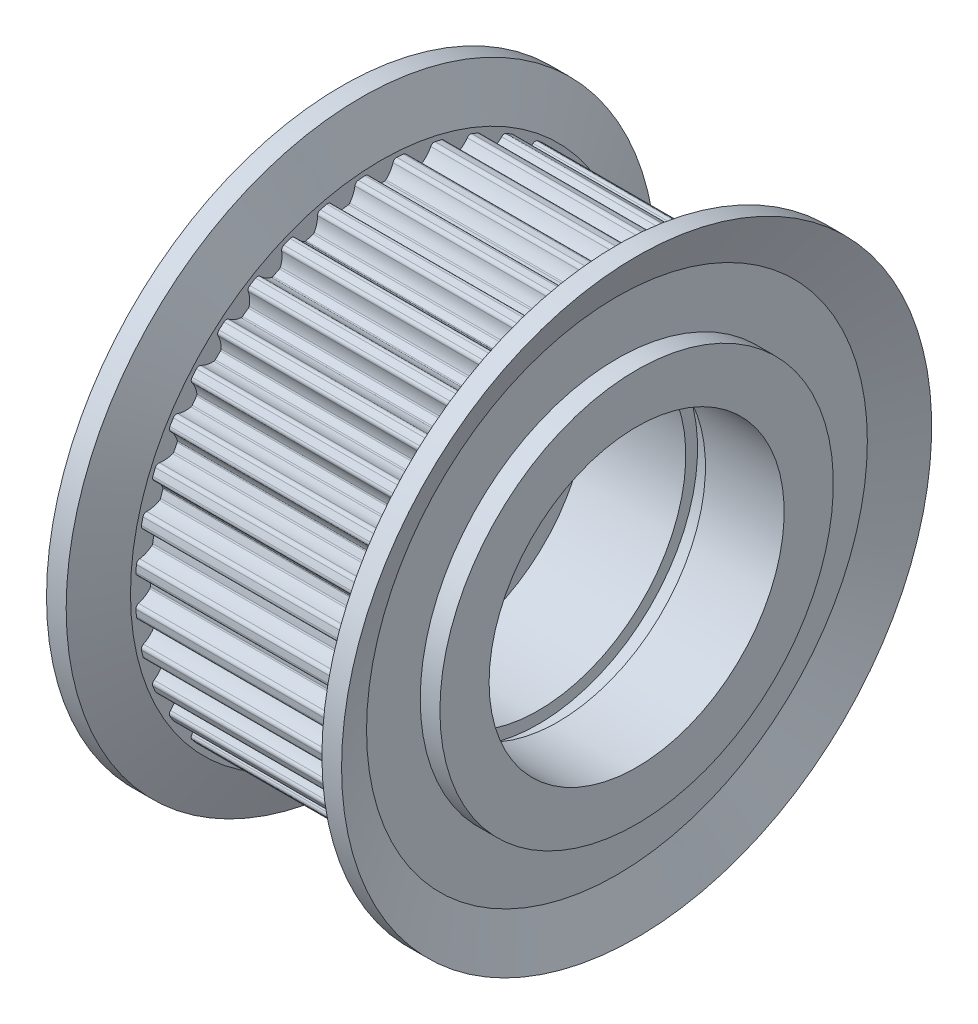
from build123d import *

# Parameters (mm, degrees)
CUT_EXTRUDE1_DEPTH  = 11
CUT_EXTRUDE2_DEPTH  = 11
CUT_EXTRUDE3_DEPTH  = 11
CUT_EXTRUDE4_DEPTH  = 11
CUT_EXTRUDE5_DEPTH  = 11
CUT_EXTRUDE6_DEPTH  = 11
CUT_EXTRUDE7_DEPTH  = 11
CUT_EXTRUDE8_DEPTH  = 11
CUT_EXTRUDE9_DEPTH  = 11
CUT_EXTRUDE10_DEPTH = 11
CUT_EXTRUDE11_DEPTH = 11
CUT_EXTRUDE12_DEPTH = 11
CUT_EXTRUDE13_DEPTH = 11
CUT_EXTRUDE14_DEPTH = 11
CUT_EXTRUDE15_DEPTH = 11
CUT_EXTRUDE16_DEPTH = 11
CUT_EXTRUDE17_DEPTH = 11
CUT_EXTRUDE18_DEPTH = 11
CUT_EXTRUDE19_DEPTH = 11
CUT_EXTRUDE20_DEPTH = 11
CUT_EXTRUDE21_DEPTH = 11
CUT_EXTRUDE22_DEPTH = 11
CUT_EXTRUDE23_DEPTH = 11
CUT_EXTRUDE24_DEPTH = 11
CUT_EXTRUDE25_DEPTH = 11
CUT_EXTRUDE26_DEPTH = 11
CUT_EXTRUDE27_DEPTH = 11
CUT_EXTRUDE28_DEPTH = 11
CUT_EXTRUDE29_DEPTH = 11
CUT_EXTRUDE30_DEPTH = 11
CUT_EXTRUDE31_DEPTH = 11
CUT_EXTRUDE32_DEPTH = 11
CUT_EXTRUDE33_DEPTH = 11
CUT_EXTRUDE34_DEPTH = 11
CUT_EXTRUDE35_DEPTH = 11
CUT_EXTRUDE36_DEPTH = 11
CUT_EXTRUDE37_DEPTH = 11
CUT_EXTRUDE38_DEPTH = 11
CUT_EXTRUDE39_DEPTH = 11
CUT_EXTRUDE40_DEPTH = 11


with BuildPart() as part:
    # Sketch1 → Revolve1 (revolve)
    with BuildSketch(Plane.XY):
        Polygon((-7.5, 6.5), (-2.5, 6.5), (-2.5, 7.5), (2.5, 7.5), (2.5, 8.1), (3.5, 8.1), (3.5, 7.5), (7.5, 7.5), (7.5, 10), (6.5, 10), (6.5, 12.73), (7.5, 15), (6.5, 15), (5.5, 12.73), (5.5, 12.48), (-5.5, 12.48), (-5.5, 12.73), (-6.5, 15), (-7.5, 15), (-6.5, 12.73), (-6.5, 10), (-7.5, 10), align=None)
    revolve(axis=Axis((15, 0, 0), (-1, 0, 0)))

    # Sketch2 → Cut-Extrude1 (cut)
    with BuildSketch(Plane(origin=(5.5, 0, 0), x_dir=(0, 0, -1), z_dir=(1, 0, 0))):
        with BuildLine():
            Line((0.809176121, 12.45373976), (0.809176121, 13.214448556))
            ThreePointArc((0.809176121, 13.214448556), (0, 13.2392), (-0.809176121, 13.214448556))
            Line((-0.809176121, 13.214448556), (-0.809176121, 12.45373976))
            ThreePointArc((-0.809176121, 12.45373976), (-0.689195108, 12.420692841), (-0.615402933, 12.320481778))
            ThreePointArc((-0.615402933, 12.320481778), (-0.472569179, 12.009502872), (-0.254854193, 11.745477217))
            ThreePointArc((-0.254854193, 11.745477217), (-0.222536107, 11.725221856), (-0.18498492, 11.718540036))
            ThreePointArc((-0.18498492, 11.718540036), (1.1e-08, 11.72), (0.184984941, 11.718540036))
            ThreePointArc((0.184984941, 11.718540036), (0.222536117, 11.72522186), (0.254854193, 11.745477217))
            ThreePointArc((0.254854193, 11.745477217), (0.472569174, 12.009502865), (0.615402928, 12.320481761))
            ThreePointArc((0.615402928, 12.320481761), (0.689195101, 12.420692836), (0.809176121, 12.45373976))
        make_face()
    extrude(amount=-CUT_EXTRUDE1_DEPTH, mode=Mode.SUBTRACT)

    # Sketch3 → Cut-Extrude2 (cut)
    with BuildSketch(Plane(origin=(5.5, 0, 0), x_dir=(0, 0, -1), z_dir=(1, 0, 0))):
        with BuildLine():
            Line((2.747407937, 12.173830524), (2.866409011, 12.925173733))
            ThreePointArc((2.866409011, 12.925173733), (2.07106717, 13.076203479), (1.267981371, 13.1783398))
            Line((1.267981371, 13.1783398), (1.148980297, 12.426996591))
            ThreePointArc((1.148980297, 12.426996591), (1.262314468, 12.37558737), (1.319521674, 12.265066431))
            ThreePointArc((1.319521674, 12.265066431), (1.411949089, 11.93557207), (1.58568093, 11.640738881))
            ThreePointArc((1.58568093, 11.640738881), (1.61443249, 11.615677235), (1.650476093, 11.60320338))
            ThreePointArc((1.650476093, 11.60320338), (1.833411941, 11.57570735), (2.015891011, 11.545327342))
            ThreePointArc((2.015891011, 11.545327342), (2.054025137, 11.546052603), (2.08911396, 11.561002923))
            ThreePointArc((2.08911396, 11.561002923), (2.345451219, 11.78771985), (2.53517427, 12.072525958))
            ThreePointArc((2.53517427, 12.072525958), (2.623734404, 12.15995963), (2.747407937, 12.173830524))
        make_face()
    extrude(amount=-CUT_EXTRUDE2_DEPTH, mode=Mode.SUBTRACT)

    # Sketch4 → Cut-Extrude3 (cut)
    with BuildSketch(Plane(origin=(5.5, 0, 0), x_dir=(0, 0, -1), z_dir=(1, 0, 0))):
        with BuildLine():
            Line((4.617989452, 11.594161178), (4.853061398, 12.317638236))
            ThreePointArc((4.853061398, 12.317638236), (4.091137792, 12.591227431), (3.313916953, 12.817736581))
            Line((3.313916953, 12.817736581), (3.078845007, 12.094259524))
            ThreePointArc((3.078845007, 12.094259524), (3.182741671, 12.025753865), (3.221955278, 11.907644444))
            ThreePointArc((3.221955278, 11.907644444), (3.261700485, 11.567747871), (3.387171326, 11.249366921))
            ThreePointArc((3.387171326, 11.249366921), (3.411648402, 11.22011609), (3.445296907, 11.202157347))
            ThreePointArc((3.445296907, 11.202157347), (3.621679184, 11.146382368), (3.797159154, 11.087830372))
            ThreePointArc((3.797159154, 11.087830372), (3.834937242, 11.082581213), (3.871932808, 11.091858367))
            ThreePointArc((3.871932808, 11.091858367), (4.160580471, 11.275684051), (4.392521208, 11.527304499))
            ThreePointArc((4.392521208, 11.527304499), (4.49366866, 11.59980786), (4.617989452, 11.594161178))
        make_face()
    extrude(amount=-CUT_EXTRUDE3_DEPTH, mode=Mode.SUBTRACT)

    # Sketch5 → Cut-Extrude4 (cut)
    with BuildSketch(Plane(origin=(5.5, 0, 0), x_dir=(0, 0, -1), z_dir=(1, 0, 0))):
        with BuildLine():
            Line((6.37486074, 10.729005105), (6.720215307, 11.406801606))
            ThreePointArc((6.720215307, 11.406801606), (6.010471024, 11.796213575), (5.278252901, 12.141518149))
            Line((5.278252901, 12.141518149), (4.932898334, 11.463721648))
            ThreePointArc((4.932898334, 11.463721648), (5.024799213, 11.379806388), (5.045053651, 11.257016731))
            ThreePointArc((5.045053651, 11.257016731), (5.031137989, 10.915087329), (5.105258322, 10.580998213))
            ThreePointArc((5.105258322, 10.580998213), (5.124858207, 10.54827845), (5.155283077, 10.525277022))
            ThreePointArc((5.155283077, 10.525277022), (5.320768666, 10.442596459), (5.484928636, 10.35731422))
            ThreePointArc((5.484928636, 10.35731422), (5.521420464, 10.346219892), (5.55941182, 10.349595447))
            ThreePointArc((5.55941182, 10.349595447), (5.873262424, 10.486003489), (6.141709696, 10.698242547))
            ThreePointArc((6.141709696, 10.698242547), (6.252953879, 10.754030324), (6.37486074, 10.729005105))
        make_face()
    extrude(amount=-CUT_EXTRUDE4_DEPTH, mode=Mode.SUBTRACT)

    # Sketch6 → Cut-Extrude5 (cut)
    with BuildSketch(Plane(origin=(5.5, 0, 0), x_dir=(0, 0, -1), z_dir=(1, 0, 0))):
        with BuildLine():
            Line((7.9747618, 9.599665319), (8.421895212, 10.215091663))
            ThreePointArc((8.421895212, 10.215091663), (7.781806512, 10.710737792), (7.112620745, 11.166335244))
            Line((7.112620745, 11.166335244), (6.665487334, 10.550908899))
            ThreePointArc((6.665487334, 10.550908899), (6.743129521, 10.453650311), (6.743926059, 10.329203906))
            ThreePointArc((6.743926059, 10.329203906), (6.676692179, 9.993661112), (6.697636916, 9.652090212))
            ThreePointArc((6.697636916, 9.652090212), (6.711876994, 9.616707186), (6.738329068, 9.589229446))
            ThreePointArc((6.738329068, 9.589229446), (6.888843165, 9.481679168), (7.037640973, 9.371766618))
            ThreePointArc((7.037640973, 9.371766618), (7.071947989, 9.3551003), (7.109999663, 9.352491139))
            ThreePointArc((7.109999663, 9.352491139), (7.441325164, 9.438122721), (7.739668907, 9.605754358))
            ThreePointArc((7.739668907, 9.605754358), (7.858270621, 9.64345287), (7.9747618, 9.599665319))
        make_face()
    extrude(amount=-CUT_EXTRUDE5_DEPTH, mode=Mode.SUBTRACT)

    # Sketch7 → Cut-Extrude6 (cut)
    with BuildSketch(Plane(origin=(5.5, 0, 0), x_dir=(0, 0, -1), z_dir=(1, 0, 0))):
        with BuildLine():
            Line((9.378297757, 8.233949913), (9.916200106, 8.771852262))
            ThreePointArc((9.916200106, 8.771852262), (9.361528097, 9.361528097), (8.771852262, 9.916200106))
            Line((8.771852262, 9.916200106), (8.233949913, 9.378297757))
            ThreePointArc((8.233949913, 9.378297757), (8.295421601, 9.27009067), (8.276740625, 9.1470518))
            ThreePointArc((8.276740625, 9.1470518), (8.157844049, 8.82615779), (8.12509746, 8.485515717))
            ThreePointArc((8.12509746, 8.485515717), (8.133627095, 8.448340676), (8.155455034, 8.417063217))
            ThreePointArc((8.155455034, 8.417063217), (8.287291483, 8.287291468), (8.417063231, 8.155455019))
            ThreePointArc((8.417063231, 8.155455019), (8.448340685, 8.133627091), (8.485515717, 8.12509746))
            ThreePointArc((8.485515717, 8.12509746), (8.826157782, 8.157844047), (9.147051784, 8.276740617))
            ThreePointArc((9.147051784, 8.276740617), (9.270090661, 8.295421602), (9.378297757, 8.233949913))
        make_face()
    extrude(amount=-CUT_EXTRUDE6_DEPTH, mode=Mode.SUBTRACT)

    # Sketch8 → Cut-Extrude7 (cut)
    with BuildSketch(Plane(origin=(5.5, 0, 0), x_dir=(0, 0, -1), z_dir=(1, 0, 0))):
        with BuildLine():
            Line((10.550908899, 6.665487334), (11.166335244, 7.112620745))
            ThreePointArc((11.166335244, 7.112620745), (10.710737792, 7.781806512), (10.215091663, 8.421895212))
            Line((10.215091663, 8.421895212), (9.599665319, 7.9747618))
            ThreePointArc((9.599665319, 7.9747618), (9.64345287, 7.85827063), (9.605754369, 7.739668922))
            ThreePointArc((9.605754369, 7.739668922), (9.438122724, 7.441325172), (9.352491139, 7.109999663))
            ThreePointArc((9.352491139, 7.109999663), (9.355100302, 7.071947979), (9.371766631, 7.037640956))
            ThreePointArc((9.371766631, 7.037640956), (9.48167918, 6.888843148), (9.589229459, 6.73832905))
            ThreePointArc((9.589229459, 6.73832905), (9.616707195, 6.711876989), (9.652090212, 6.697636916))
            ThreePointArc((9.652090212, 6.697636916), (9.993661103, 6.676692179), (10.329203889, 6.743926053))
            ThreePointArc((10.329203889, 6.743926053), (10.453650303, 6.743129524), (10.550908899, 6.665487334))
        make_face()
    extrude(amount=-CUT_EXTRUDE7_DEPTH, mode=Mode.SUBTRACT)

    # Sketch9 → Cut-Extrude8 (cut)
    with BuildSketch(Plane(origin=(5.5, 0, 0), x_dir=(0, 0, -1), z_dir=(1, 0, 0))):
        with BuildLine():
            Line((11.463721648, 4.932898334), (12.141518149, 5.278252901))
            ThreePointArc((12.141518149, 5.278252901), (11.796213575, 6.010471024), (11.406801606, 6.720215307))
            Line((11.406801606, 6.720215307), (10.729005105, 6.37486074))
            ThreePointArc((10.729005105, 6.37486074), (10.754030325, 6.252953888), (10.69824256, 6.141709708))
            ThreePointArc((10.69824256, 6.141709708), (10.486003494, 5.873262432), (10.349595447, 5.55941182))
            ThreePointArc((10.349595447, 5.55941182), (10.346219893, 5.521420453), (10.35731423, 5.484928618))
            ThreePointArc((10.35731423, 5.484928618), (10.442596468, 5.320768648), (10.525277032, 5.155283058))
            ThreePointArc((10.525277032, 5.155283058), (10.548278457, 5.1248582), (10.580998213, 5.105258322))
            ThreePointArc((10.580998213, 5.105258322), (10.91508732, 5.03113799), (11.257016713, 5.045053648))
            ThreePointArc((11.257016713, 5.045053648), (11.37980638, 5.024799217), (11.463721648, 4.932898334))
        make_face()
    extrude(amount=-CUT_EXTRUDE8_DEPTH, mode=Mode.SUBTRACT)

    # Sketch10 → Cut-Extrude9 (cut)
    with BuildSketch(Plane(origin=(5.5, 0, 0), x_dir=(0, 0, -1), z_dir=(1, 0, 0))):
        with BuildLine():
            Line((12.094259524, 3.078845007), (12.817736581, 3.313916953))
            ThreePointArc((12.817736581, 3.313916953), (12.591227431, 4.091137792), (12.317638236, 4.853061398))
            Line((12.317638236, 4.853061398), (11.594161178, 4.617989452))
            ThreePointArc((11.594161178, 4.617989452), (11.599807863, 4.493668668), (11.527304514, 4.392521218))
            ThreePointArc((11.527304514, 4.392521218), (11.275684057, 4.160580478), (11.091858367, 3.871932808))
            ThreePointArc((11.091858367, 3.871932808), (11.082581212, 3.834937231), (11.087830379, 3.797159134))
            ThreePointArc((11.087830379, 3.797159134), (11.146382374, 3.621679164), (11.202157353, 3.445296887))
            ThreePointArc((11.202157353, 3.445296887), (11.220116097, 3.411648393), (11.249366921, 3.387171326))
            ThreePointArc((11.249366921, 3.387171326), (11.567747863, 3.261700487), (11.907644426, 3.221955278))
            ThreePointArc((11.907644426, 3.221955278), (12.025753857, 3.182741677), (12.094259524, 3.078845007))
        make_face()
    extrude(amount=-CUT_EXTRUDE9_DEPTH, mode=Mode.SUBTRACT)

    # Sketch11 → Cut-Extrude10 (cut)
    with BuildSketch(Plane(origin=(5.5, 0, 0), x_dir=(0, 0, -1), z_dir=(1, 0, 0))):
        with BuildLine():
            Line((12.426996591, 1.148980297), (13.1783398, 1.267981371))
            ThreePointArc((13.1783398, 1.267981371), (13.076203479, 2.07106717), (12.925173733, 2.866409011))
            Line((12.925173733, 2.866409011), (12.173830524, 2.747407937))
            ThreePointArc((12.173830524, 2.747407937), (12.159959634, 2.623734413), (12.072525974, 2.535174278))
            ThreePointArc((12.072525974, 2.535174278), (11.787719857, 2.345451225), (11.561002923, 2.08911396))
            ThreePointArc((11.561002923, 2.08911396), (11.546052601, 2.054025127), (11.545327346, 2.01589099))
            ThreePointArc((11.545327346, 2.01589099), (11.575707353, 1.83341192), (11.603203382, 1.650476072))
            ThreePointArc((11.603203382, 1.650476072), (11.61567724, 1.614432481), (11.640738881, 1.58568093))
            ThreePointArc((11.640738881, 1.58568093), (11.935572062, 1.411949093), (12.265066414, 1.319521676))
            ThreePointArc((12.265066414, 1.319521676), (12.375587363, 1.262314474), (12.426996591, 1.148980297))
        make_face()
    extrude(amount=-CUT_EXTRUDE10_DEPTH, mode=Mode.SUBTRACT)

    # Sketch12 → Cut-Extrude11 (cut)
    with BuildSketch(Plane(origin=(5.5, 0, 0), x_dir=(0, 0, -1), z_dir=(1, 0, 0))):
        with BuildLine():
            Line((12.45373976, -0.809176121), (13.214448556, -0.809176121))
            ThreePointArc((13.214448556, -0.809176121), (13.2392, 0), (13.214448556, 0.809176121))
            Line((13.214448556, 0.809176121), (12.45373976, 0.809176121))
            ThreePointArc((12.45373976, 0.809176121), (12.420692841, 0.689195108), (12.320481778, 0.615402933))
            ThreePointArc((12.320481778, 0.615402933), (12.009502872, 0.472569179), (11.745477217, 0.254854193))
            ThreePointArc((11.745477217, 0.254854193), (11.725221856, 0.222536107), (11.718540036, 0.18498492))
            ThreePointArc((11.718540036, 0.18498492), (11.72, -1.1e-08), (11.718540036, -0.184984941))
            ThreePointArc((11.718540036, -0.184984941), (11.72522186, -0.222536117), (11.745477217, -0.254854193))
            ThreePointArc((11.745477217, -0.254854193), (12.009502865, -0.472569174), (12.320481761, -0.615402928))
            ThreePointArc((12.320481761, -0.615402928), (12.420692836, -0.689195101), (12.45373976, -0.809176121))
        make_face()
    extrude(amount=-CUT_EXTRUDE11_DEPTH, mode=Mode.SUBTRACT)

    # Sketch13 → Cut-Extrude12 (cut)
    with BuildSketch(Plane(origin=(5.5, 0, 0), x_dir=(0, 0, -1), z_dir=(1, 0, 0))):
        with BuildLine():
            Line((12.173830524, -2.747407937), (12.925173733, -2.866409011))
            ThreePointArc((12.925173733, -2.866409011), (13.076203479, -2.07106717), (13.1783398, -1.267981371))
            Line((13.1783398, -1.267981371), (12.426996591, -1.148980297))
            ThreePointArc((12.426996591, -1.148980297), (12.37558737, -1.262314468), (12.265066431, -1.319521674))
            ThreePointArc((12.265066431, -1.319521674), (11.93557207, -1.411949089), (11.640738881, -1.58568093))
            ThreePointArc((11.640738881, -1.58568093), (11.615677235, -1.61443249), (11.60320338, -1.650476093))
            ThreePointArc((11.60320338, -1.650476093), (11.57570735, -1.833411941), (11.545327342, -2.015891011))
            ThreePointArc((11.545327342, -2.015891011), (11.546052603, -2.054025137), (11.561002923, -2.08911396))
            ThreePointArc((11.561002923, -2.08911396), (11.78771985, -2.345451219), (12.072525958, -2.53517427))
            ThreePointArc((12.072525958, -2.53517427), (12.15995963, -2.623734404), (12.173830524, -2.747407937))
        make_face()
    extrude(amount=-CUT_EXTRUDE12_DEPTH, mode=Mode.SUBTRACT)

    # Sketch14 → Cut-Extrude13 (cut)
    with BuildSketch(Plane(origin=(5.5, 0, 0), x_dir=(0, 0, -1), z_dir=(1, 0, 0))):
        with BuildLine():
            Line((11.594161178, -4.617989452), (12.317638236, -4.853061398))
            ThreePointArc((12.317638236, -4.853061398), (12.591227431, -4.091137792), (12.817736581, -3.313916953))
            Line((12.817736581, -3.313916953), (12.094259524, -3.078845007))
            ThreePointArc((12.094259524, -3.078845007), (12.025753865, -3.182741671), (11.907644444, -3.221955278))
            ThreePointArc((11.907644444, -3.221955278), (11.567747871, -3.261700485), (11.249366921, -3.387171326))
            ThreePointArc((11.249366921, -3.387171326), (11.22011609, -3.411648402), (11.202157347, -3.445296907))
            ThreePointArc((11.202157347, -3.445296907), (11.146382368, -3.621679184), (11.087830372, -3.797159154))
            ThreePointArc((11.087830372, -3.797159154), (11.082581213, -3.834937242), (11.091858367, -3.871932808))
            ThreePointArc((11.091858367, -3.871932808), (11.275684051, -4.160580471), (11.527304499, -4.392521208))
            ThreePointArc((11.527304499, -4.392521208), (11.59980786, -4.49366866), (11.594161178, -4.617989452))
        make_face()
    extrude(amount=-CUT_EXTRUDE13_DEPTH, mode=Mode.SUBTRACT)

    # Sketch15 → Cut-Extrude14 (cut)
    with BuildSketch(Plane(origin=(5.5, 0, 0), x_dir=(0, 0, -1), z_dir=(1, 0, 0))):
        with BuildLine():
            Line((10.729005105, -6.37486074), (11.406801606, -6.720215307))
            ThreePointArc((11.406801606, -6.720215307), (11.796213575, -6.010471024), (12.141518149, -5.278252901))
            Line((12.141518149, -5.278252901), (11.463721648, -4.932898334))
            ThreePointArc((11.463721648, -4.932898334), (11.379806388, -5.024799213), (11.257016731, -5.045053651))
            ThreePointArc((11.257016731, -5.045053651), (10.915087329, -5.031137989), (10.580998213, -5.105258322))
            ThreePointArc((10.580998213, -5.105258322), (10.54827845, -5.124858207), (10.525277022, -5.155283077))
            ThreePointArc((10.525277022, -5.155283077), (10.442596459, -5.320768666), (10.35731422, -5.484928636))
            ThreePointArc((10.35731422, -5.484928636), (10.346219892, -5.521420464), (10.349595447, -5.55941182))
            ThreePointArc((10.349595447, -5.55941182), (10.486003489, -5.873262424), (10.698242547, -6.141709696))
            ThreePointArc((10.698242547, -6.141709696), (10.754030324, -6.252953879), (10.729005105, -6.37486074))
        make_face()
    extrude(amount=-CUT_EXTRUDE14_DEPTH, mode=Mode.SUBTRACT)

    # Sketch16 → Cut-Extrude15 (cut)
    with BuildSketch(Plane(origin=(5.5, 0, 0), x_dir=(0, 0, -1), z_dir=(1, 0, 0))):
        with BuildLine():
            Line((9.599665319, -7.9747618), (10.215091663, -8.421895212))
            ThreePointArc((10.215091663, -8.421895212), (10.710737792, -7.781806512), (11.166335244, -7.112620745))
            Line((11.166335244, -7.112620745), (10.550908899, -6.665487334))
            ThreePointArc((10.550908899, -6.665487334), (10.453650311, -6.743129521), (10.329203906, -6.743926059))
            ThreePointArc((10.329203906, -6.743926059), (9.993661112, -6.676692179), (9.652090212, -6.697636916))
            ThreePointArc((9.652090212, -6.697636916), (9.616707186, -6.711876994), (9.589229446, -6.738329068))
            ThreePointArc((9.589229446, -6.738329068), (9.481679168, -6.888843165), (9.371766618, -7.037640973))
            ThreePointArc((9.371766618, -7.037640973), (9.3551003, -7.071947989), (9.352491139, -7.109999663))
            ThreePointArc((9.352491139, -7.109999663), (9.438122721, -7.441325164), (9.605754358, -7.739668907))
            ThreePointArc((9.605754358, -7.739668907), (9.64345287, -7.858270621), (9.599665319, -7.9747618))
        make_face()
    extrude(amount=-CUT_EXTRUDE15_DEPTH, mode=Mode.SUBTRACT)

    # Sketch17 → Cut-Extrude16 (cut)
    with BuildSketch(Plane(origin=(5.5, 0, 0), x_dir=(0, 0, -1), z_dir=(1, 0, 0))):
        with BuildLine():
            Line((8.233949913, -9.378297757), (8.771852262, -9.916200106))
            ThreePointArc((8.771852262, -9.916200106), (9.361528097, -9.361528097), (9.916200106, -8.771852262))
            Line((9.916200106, -8.771852262), (9.378297757, -8.233949913))
            ThreePointArc((9.378297757, -8.233949913), (9.27009067, -8.295421601), (9.1470518, -8.276740625))
            ThreePointArc((9.1470518, -8.276740625), (8.82615779, -8.157844049), (8.485515717, -8.12509746))
            ThreePointArc((8.485515717, -8.12509746), (8.448340676, -8.133627095), (8.417063217, -8.155455034))
            ThreePointArc((8.417063217, -8.155455034), (8.287291468, -8.287291483), (8.155455019, -8.417063231))
            ThreePointArc((8.155455019, -8.417063231), (8.133627091, -8.448340685), (8.12509746, -8.485515717))
            ThreePointArc((8.12509746, -8.485515717), (8.157844047, -8.826157782), (8.276740617, -9.147051784))
            ThreePointArc((8.276740617, -9.147051784), (8.295421602, -9.270090661), (8.233949913, -9.378297757))
        make_face()
    extrude(amount=-CUT_EXTRUDE16_DEPTH, mode=Mode.SUBTRACT)

    # Sketch18 → Cut-Extrude17 (cut)
    with BuildSketch(Plane(origin=(5.5, 0, 0), x_dir=(0, 0, -1), z_dir=(1, 0, 0))):
        with BuildLine():
            Line((6.665487334, -10.550908899), (7.112620745, -11.166335244))
            ThreePointArc((7.112620745, -11.166335244), (7.781806512, -10.710737792), (8.421895212, -10.215091663))
            Line((8.421895212, -10.215091663), (7.9747618, -9.599665319))
            ThreePointArc((7.9747618, -9.599665319), (7.85827063, -9.64345287), (7.739668922, -9.605754369))
            ThreePointArc((7.739668922, -9.605754369), (7.441325172, -9.438122724), (7.109999663, -9.352491139))
            ThreePointArc((7.109999663, -9.352491139), (7.071947979, -9.355100302), (7.037640956, -9.371766631))
            ThreePointArc((7.037640956, -9.371766631), (6.888843148, -9.48167918), (6.73832905, -9.589229459))
            ThreePointArc((6.73832905, -9.589229459), (6.711876989, -9.616707195), (6.697636916, -9.652090212))
            ThreePointArc((6.697636916, -9.652090212), (6.676692179, -9.993661103), (6.743926053, -10.329203889))
            ThreePointArc((6.743926053, -10.329203889), (6.743129524, -10.453650303), (6.665487334, -10.550908899))
        make_face()
    extrude(amount=-CUT_EXTRUDE17_DEPTH, mode=Mode.SUBTRACT)

    # Sketch19 → Cut-Extrude18 (cut)
    with BuildSketch(Plane(origin=(5.5, 0, 0), x_dir=(0, 0, -1), z_dir=(1, 0, 0))):
        with BuildLine():
            Line((4.932898334, -11.463721648), (5.278252901, -12.141518149))
            ThreePointArc((5.278252901, -12.141518149), (6.010471024, -11.796213575), (6.720215307, -11.406801606))
            Line((6.720215307, -11.406801606), (6.37486074, -10.729005105))
            ThreePointArc((6.37486074, -10.729005105), (6.252953888, -10.754030325), (6.141709708, -10.69824256))
            ThreePointArc((6.141709708, -10.69824256), (5.873262432, -10.486003494), (5.55941182, -10.349595447))
            ThreePointArc((5.55941182, -10.349595447), (5.521420453, -10.346219893), (5.484928618, -10.35731423))
            ThreePointArc((5.484928618, -10.35731423), (5.320768648, -10.442596468), (5.155283058, -10.525277032))
            ThreePointArc((5.155283058, -10.525277032), (5.1248582, -10.548278457), (5.105258322, -10.580998213))
            ThreePointArc((5.105258322, -10.580998213), (5.03113799, -10.91508732), (5.045053648, -11.257016713))
            ThreePointArc((5.045053648, -11.257016713), (5.024799217, -11.37980638), (4.932898334, -11.463721648))
        make_face()
    extrude(amount=-CUT_EXTRUDE18_DEPTH, mode=Mode.SUBTRACT)

    # Sketch20 → Cut-Extrude19 (cut)
    with BuildSketch(Plane(origin=(5.5, 0, 0), x_dir=(0, 0, -1), z_dir=(1, 0, 0))):
        with BuildLine():
            Line((3.078845007, -12.094259524), (3.313916953, -12.817736581))
            ThreePointArc((3.313916953, -12.817736581), (4.091137792, -12.591227431), (4.853061398, -12.317638236))
            Line((4.853061398, -12.317638236), (4.617989452, -11.594161178))
            ThreePointArc((4.617989452, -11.594161178), (4.493668668, -11.599807863), (4.392521218, -11.527304514))
            ThreePointArc((4.392521218, -11.527304514), (4.160580478, -11.275684057), (3.871932808, -11.091858367))
            ThreePointArc((3.871932808, -11.091858367), (3.834937231, -11.082581212), (3.797159134, -11.087830379))
            ThreePointArc((3.797159134, -11.087830379), (3.621679164, -11.146382374), (3.445296887, -11.202157353))
            ThreePointArc((3.445296887, -11.202157353), (3.411648393, -11.220116097), (3.387171326, -11.249366921))
            ThreePointArc((3.387171326, -11.249366921), (3.261700487, -11.567747863), (3.221955278, -11.907644426))
            ThreePointArc((3.221955278, -11.907644426), (3.182741677, -12.025753857), (3.078845007, -12.094259524))
        make_face()
    extrude(amount=-CUT_EXTRUDE19_DEPTH, mode=Mode.SUBTRACT)

    # Sketch21 → Cut-Extrude20 (cut)
    with BuildSketch(Plane(origin=(5.5, 0, 0), x_dir=(0, 0, -1), z_dir=(1, 0, 0))):
        with BuildLine():
            Line((1.148980297, -12.426996591), (1.267981371, -13.1783398))
            ThreePointArc((1.267981371, -13.1783398), (2.07106717, -13.076203479), (2.866409011, -12.925173733))
            Line((2.866409011, -12.925173733), (2.747407937, -12.173830524))
            ThreePointArc((2.747407937, -12.173830524), (2.623734413, -12.159959634), (2.535174278, -12.072525974))
            ThreePointArc((2.535174278, -12.072525974), (2.345451225, -11.787719857), (2.08911396, -11.561002923))
            ThreePointArc((2.08911396, -11.561002923), (2.054025127, -11.546052601), (2.01589099, -11.545327346))
            ThreePointArc((2.01589099, -11.545327346), (1.83341192, -11.575707353), (1.650476072, -11.603203382))
            ThreePointArc((1.650476072, -11.603203382), (1.614432481, -11.61567724), (1.58568093, -11.640738881))
            ThreePointArc((1.58568093, -11.640738881), (1.411949093, -11.935572062), (1.319521676, -12.265066414))
            ThreePointArc((1.319521676, -12.265066414), (1.262314474, -12.375587363), (1.148980297, -12.426996591))
        make_face()
    extrude(amount=-CUT_EXTRUDE20_DEPTH, mode=Mode.SUBTRACT)

    # Sketch22 → Cut-Extrude21 (cut)
    with BuildSketch(Plane(origin=(5.5, 0, 0), x_dir=(0, 0, -1), z_dir=(1, 0, 0))):
        with BuildLine():
            Line((-0.809176121, -12.45373976), (-0.809176121, -13.214448556))
            ThreePointArc((-0.809176121, -13.214448556), (0, -13.2392), (0.809176121, -13.214448556))
            Line((0.809176121, -13.214448556), (0.809176121, -12.45373976))
            ThreePointArc((0.809176121, -12.45373976), (0.689195108, -12.420692841), (0.615402933, -12.320481778))
            ThreePointArc((0.615402933, -12.320481778), (0.472569179, -12.009502872), (0.254854193, -11.745477217))
            ThreePointArc((0.254854193, -11.745477217), (0.222536107, -11.725221856), (0.18498492, -11.718540036))
            ThreePointArc((0.18498492, -11.718540036), (-1.1e-08, -11.72), (-0.184984941, -11.718540036))
            ThreePointArc((-0.184984941, -11.718540036), (-0.222536117, -11.72522186), (-0.254854193, -11.745477217))
            ThreePointArc((-0.254854193, -11.745477217), (-0.472569174, -12.009502865), (-0.615402928, -12.320481761))
            ThreePointArc((-0.615402928, -12.320481761), (-0.689195101, -12.420692836), (-0.809176121, -12.45373976))
        make_face()
    extrude(amount=-CUT_EXTRUDE21_DEPTH, mode=Mode.SUBTRACT)

    # Sketch23 → Cut-Extrude22 (cut)
    with BuildSketch(Plane(origin=(5.5, 0, 0), x_dir=(0, 0, -1), z_dir=(1, 0, 0))):
        with BuildLine():
            Line((-2.747407937, -12.173830524), (-2.866409011, -12.925173733))
            ThreePointArc((-2.866409011, -12.925173733), (-2.07106717, -13.076203479), (-1.267981371, -13.1783398))
            Line((-1.267981371, -13.1783398), (-1.148980297, -12.426996591))
            ThreePointArc((-1.148980297, -12.426996591), (-1.262314468, -12.37558737), (-1.319521674, -12.265066431))
            ThreePointArc((-1.319521674, -12.265066431), (-1.411949089, -11.93557207), (-1.58568093, -11.640738881))
            ThreePointArc((-1.58568093, -11.640738881), (-1.61443249, -11.615677235), (-1.650476093, -11.60320338))
            ThreePointArc((-1.650476093, -11.60320338), (-1.833411941, -11.57570735), (-2.015891011, -11.545327342))
            ThreePointArc((-2.015891011, -11.545327342), (-2.054025137, -11.546052603), (-2.08911396, -11.561002923))
            ThreePointArc((-2.08911396, -11.561002923), (-2.345451219, -11.78771985), (-2.53517427, -12.072525958))
            ThreePointArc((-2.53517427, -12.072525958), (-2.623734404, -12.15995963), (-2.747407937, -12.173830524))
        make_face()
    extrude(amount=-CUT_EXTRUDE22_DEPTH, mode=Mode.SUBTRACT)

    # Sketch24 → Cut-Extrude23 (cut)
    with BuildSketch(Plane(origin=(5.5, 0, 0), x_dir=(0, 0, -1), z_dir=(1, 0, 0))):
        with BuildLine():
            Line((-4.617989452, -11.594161178), (-4.853061398, -12.317638236))
            ThreePointArc((-4.853061398, -12.317638236), (-4.091137792, -12.591227431), (-3.313916953, -12.817736581))
            Line((-3.313916953, -12.817736581), (-3.078845007, -12.094259524))
            ThreePointArc((-3.078845007, -12.094259524), (-3.182741671, -12.025753865), (-3.221955278, -11.907644444))
            ThreePointArc((-3.221955278, -11.907644444), (-3.261700485, -11.567747871), (-3.387171326, -11.249366921))
            ThreePointArc((-3.387171326, -11.249366921), (-3.411648402, -11.22011609), (-3.445296907, -11.202157347))
            ThreePointArc((-3.445296907, -11.202157347), (-3.621679184, -11.146382368), (-3.797159154, -11.087830372))
            ThreePointArc((-3.797159154, -11.087830372), (-3.834937242, -11.082581213), (-3.871932808, -11.091858367))
            ThreePointArc((-3.871932808, -11.091858367), (-4.160580471, -11.275684051), (-4.392521208, -11.527304499))
            ThreePointArc((-4.392521208, -11.527304499), (-4.49366866, -11.59980786), (-4.617989452, -11.594161178))
        make_face()
    extrude(amount=-CUT_EXTRUDE23_DEPTH, mode=Mode.SUBTRACT)

    # Sketch25 → Cut-Extrude24 (cut)
    with BuildSketch(Plane(origin=(5.5, 0, 0), x_dir=(0, 0, -1), z_dir=(1, 0, 0))):
        with BuildLine():
            Line((-6.37486074, -10.729005105), (-6.720215307, -11.406801606))
            ThreePointArc((-6.720215307, -11.406801606), (-6.010471024, -11.796213575), (-5.278252901, -12.141518149))
            Line((-5.278252901, -12.141518149), (-4.932898334, -11.463721648))
            ThreePointArc((-4.932898334, -11.463721648), (-5.024799213, -11.379806388), (-5.045053651, -11.257016731))
            ThreePointArc((-5.045053651, -11.257016731), (-5.031137989, -10.915087329), (-5.105258322, -10.580998213))
            ThreePointArc((-5.105258322, -10.580998213), (-5.124858207, -10.54827845), (-5.155283077, -10.525277022))
            ThreePointArc((-5.155283077, -10.525277022), (-5.320768666, -10.442596459), (-5.484928636, -10.35731422))
            ThreePointArc((-5.484928636, -10.35731422), (-5.521420464, -10.346219892), (-5.55941182, -10.349595447))
            ThreePointArc((-5.55941182, -10.349595447), (-5.873262424, -10.486003489), (-6.141709696, -10.698242547))
            ThreePointArc((-6.141709696, -10.698242547), (-6.252953879, -10.754030324), (-6.37486074, -10.729005105))
        make_face()
    extrude(amount=-CUT_EXTRUDE24_DEPTH, mode=Mode.SUBTRACT)

    # Sketch26 → Cut-Extrude25 (cut)
    with BuildSketch(Plane(origin=(5.5, 0, 0), x_dir=(0, 0, -1), z_dir=(1, 0, 0))):
        with BuildLine():
            Line((-7.9747618, -9.599665319), (-8.421895212, -10.215091663))
            ThreePointArc((-8.421895212, -10.215091663), (-7.781806512, -10.710737792), (-7.112620745, -11.166335244))
            Line((-7.112620745, -11.166335244), (-6.665487334, -10.550908899))
            ThreePointArc((-6.665487334, -10.550908899), (-6.743129521, -10.453650311), (-6.743926059, -10.329203906))
            ThreePointArc((-6.743926059, -10.329203906), (-6.676692179, -9.993661112), (-6.697636916, -9.652090212))
            ThreePointArc((-6.697636916, -9.652090212), (-6.711876994, -9.616707186), (-6.738329068, -9.589229446))
            ThreePointArc((-6.738329068, -9.589229446), (-6.888843165, -9.481679168), (-7.037640973, -9.371766618))
            ThreePointArc((-7.037640973, -9.371766618), (-7.071947989, -9.3551003), (-7.109999663, -9.352491139))
            ThreePointArc((-7.109999663, -9.352491139), (-7.441325164, -9.438122721), (-7.739668907, -9.605754358))
            ThreePointArc((-7.739668907, -9.605754358), (-7.858270621, -9.64345287), (-7.9747618, -9.599665319))
        make_face()
    extrude(amount=-CUT_EXTRUDE25_DEPTH, mode=Mode.SUBTRACT)

    # Sketch27 → Cut-Extrude26 (cut)
    with BuildSketch(Plane(origin=(5.5, 0, 0), x_dir=(0, 0, -1), z_dir=(1, 0, 0))):
        with BuildLine():
            Line((-9.378297757, -8.233949913), (-9.916200106, -8.771852262))
            ThreePointArc((-9.916200106, -8.771852262), (-9.361528097, -9.361528097), (-8.771852262, -9.916200106))
            Line((-8.771852262, -9.916200106), (-8.233949913, -9.378297757))
            ThreePointArc((-8.233949913, -9.378297757), (-8.295421601, -9.27009067), (-8.276740625, -9.1470518))
            ThreePointArc((-8.276740625, -9.1470518), (-8.157844049, -8.82615779), (-8.12509746, -8.485515717))
            ThreePointArc((-8.12509746, -8.485515717), (-8.133627095, -8.448340676), (-8.155455034, -8.417063217))
            ThreePointArc((-8.155455034, -8.417063217), (-8.287291483, -8.287291468), (-8.417063231, -8.155455019))
            ThreePointArc((-8.417063231, -8.155455019), (-8.448340685, -8.133627091), (-8.485515717, -8.12509746))
            ThreePointArc((-8.485515717, -8.12509746), (-8.826157782, -8.157844047), (-9.147051784, -8.276740617))
            ThreePointArc((-9.147051784, -8.276740617), (-9.270090661, -8.295421602), (-9.378297757, -8.233949913))
        make_face()
    extrude(amount=-CUT_EXTRUDE26_DEPTH, mode=Mode.SUBTRACT)

    # Sketch28 → Cut-Extrude27 (cut)
    with BuildSketch(Plane(origin=(5.5, 0, 0), x_dir=(0, 0, -1), z_dir=(1, 0, 0))):
        with BuildLine():
            Line((-10.550908899, -6.665487334), (-11.166335244, -7.112620745))
            ThreePointArc((-11.166335244, -7.112620745), (-10.710737792, -7.781806512), (-10.215091663, -8.421895212))
            Line((-10.215091663, -8.421895212), (-9.599665319, -7.9747618))
            ThreePointArc((-9.599665319, -7.9747618), (-9.64345287, -7.85827063), (-9.605754369, -7.739668922))
            ThreePointArc((-9.605754369, -7.739668922), (-9.438122724, -7.441325172), (-9.352491139, -7.109999663))
            ThreePointArc((-9.352491139, -7.109999663), (-9.355100302, -7.071947979), (-9.371766631, -7.037640956))
            ThreePointArc((-9.371766631, -7.037640956), (-9.48167918, -6.888843148), (-9.589229459, -6.73832905))
            ThreePointArc((-9.589229459, -6.73832905), (-9.616707195, -6.711876989), (-9.652090212, -6.697636916))
            ThreePointArc((-9.652090212, -6.697636916), (-9.993661103, -6.676692179), (-10.329203889, -6.743926053))
            ThreePointArc((-10.329203889, -6.743926053), (-10.453650303, -6.743129524), (-10.550908899, -6.665487334))
        make_face()
    extrude(amount=-CUT_EXTRUDE27_DEPTH, mode=Mode.SUBTRACT)

    # Sketch29 → Cut-Extrude28 (cut)
    with BuildSketch(Plane(origin=(5.5, 0, 0), x_dir=(0, 0, -1), z_dir=(1, 0, 0))):
        with BuildLine():
            Line((-11.463721648, -4.932898334), (-12.141518149, -5.278252901))
            ThreePointArc((-12.141518149, -5.278252901), (-11.796213575, -6.010471024), (-11.406801606, -6.720215307))
            Line((-11.406801606, -6.720215307), (-10.729005105, -6.37486074))
            ThreePointArc((-10.729005105, -6.37486074), (-10.754030325, -6.252953888), (-10.69824256, -6.141709708))
            ThreePointArc((-10.69824256, -6.141709708), (-10.486003494, -5.873262432), (-10.349595447, -5.55941182))
            ThreePointArc((-10.349595447, -5.55941182), (-10.346219893, -5.521420453), (-10.35731423, -5.484928618))
            ThreePointArc((-10.35731423, -5.484928618), (-10.442596468, -5.320768648), (-10.525277032, -5.155283058))
            ThreePointArc((-10.525277032, -5.155283058), (-10.548278457, -5.1248582), (-10.580998213, -5.105258322))
            ThreePointArc((-10.580998213, -5.105258322), (-10.91508732, -5.03113799), (-11.257016713, -5.045053648))
            ThreePointArc((-11.257016713, -5.045053648), (-11.37980638, -5.024799217), (-11.463721648, -4.932898334))
        make_face()
    extrude(amount=-CUT_EXTRUDE28_DEPTH, mode=Mode.SUBTRACT)

    # Sketch30 → Cut-Extrude29 (cut)
    with BuildSketch(Plane(origin=(5.5, 0, 0), x_dir=(0, 0, -1), z_dir=(1, 0, 0))):
        with BuildLine():
            Line((-12.094259524, -3.078845007), (-12.817736581, -3.313916953))
            ThreePointArc((-12.817736581, -3.313916953), (-12.591227431, -4.091137792), (-12.317638236, -4.853061398))
            Line((-12.317638236, -4.853061398), (-11.594161178, -4.617989452))
            ThreePointArc((-11.594161178, -4.617989452), (-11.599807863, -4.493668668), (-11.527304514, -4.392521218))
            ThreePointArc((-11.527304514, -4.392521218), (-11.275684057, -4.160580478), (-11.091858367, -3.871932808))
            ThreePointArc((-11.091858367, -3.871932808), (-11.082581212, -3.834937231), (-11.087830379, -3.797159134))
            ThreePointArc((-11.087830379, -3.797159134), (-11.146382374, -3.621679164), (-11.202157353, -3.445296887))
            ThreePointArc((-11.202157353, -3.445296887), (-11.220116097, -3.411648393), (-11.249366921, -3.387171326))
            ThreePointArc((-11.249366921, -3.387171326), (-11.567747863, -3.261700487), (-11.907644426, -3.221955278))
            ThreePointArc((-11.907644426, -3.221955278), (-12.025753857, -3.182741677), (-12.094259524, -3.078845007))
        make_face()
    extrude(amount=-CUT_EXTRUDE29_DEPTH, mode=Mode.SUBTRACT)

    # Sketch31 → Cut-Extrude30 (cut)
    with BuildSketch(Plane(origin=(5.5, 0, 0), x_dir=(0, 0, -1), z_dir=(1, 0, 0))):
        with BuildLine():
            Line((-12.426996591, -1.148980297), (-13.1783398, -1.267981371))
            ThreePointArc((-13.1783398, -1.267981371), (-13.076203479, -2.07106717), (-12.925173733, -2.866409011))
            Line((-12.925173733, -2.866409011), (-12.173830524, -2.747407937))
            ThreePointArc((-12.173830524, -2.747407937), (-12.159959634, -2.623734413), (-12.072525974, -2.535174278))
            ThreePointArc((-12.072525974, -2.535174278), (-11.787719857, -2.345451225), (-11.561002923, -2.08911396))
            ThreePointArc((-11.561002923, -2.08911396), (-11.546052601, -2.054025127), (-11.545327346, -2.01589099))
            ThreePointArc((-11.545327346, -2.01589099), (-11.575707353, -1.83341192), (-11.603203382, -1.650476072))
            ThreePointArc((-11.603203382, -1.650476072), (-11.61567724, -1.614432481), (-11.640738881, -1.58568093))
            ThreePointArc((-11.640738881, -1.58568093), (-11.935572062, -1.411949093), (-12.265066414, -1.319521676))
            ThreePointArc((-12.265066414, -1.319521676), (-12.375587363, -1.262314474), (-12.426996591, -1.148980297))
        make_face()
    extrude(amount=-CUT_EXTRUDE30_DEPTH, mode=Mode.SUBTRACT)

    # Sketch32 → Cut-Extrude31 (cut)
    with BuildSketch(Plane(origin=(5.5, 0, 0), x_dir=(0, 0, -1), z_dir=(1, 0, 0))):
        with BuildLine():
            Line((-12.45373976, 0.809176121), (-13.214448556, 0.809176121))
            ThreePointArc((-13.214448556, 0.809176121), (-13.2392, 0), (-13.214448556, -0.809176121))
            Line((-13.214448556, -0.809176121), (-12.45373976, -0.809176121))
            ThreePointArc((-12.45373976, -0.809176121), (-12.420692841, -0.689195108), (-12.320481778, -0.615402933))
            ThreePointArc((-12.320481778, -0.615402933), (-12.009502872, -0.472569179), (-11.745477217, -0.254854193))
            ThreePointArc((-11.745477217, -0.254854193), (-11.725221856, -0.222536107), (-11.718540036, -0.18498492))
            ThreePointArc((-11.718540036, -0.18498492), (-11.72, 1.1e-08), (-11.718540036, 0.184984941))
            ThreePointArc((-11.718540036, 0.184984941), (-11.72522186, 0.222536117), (-11.745477217, 0.254854193))
            ThreePointArc((-11.745477217, 0.254854193), (-12.009502865, 0.472569174), (-12.320481761, 0.615402928))
            ThreePointArc((-12.320481761, 0.615402928), (-12.420692836, 0.689195101), (-12.45373976, 0.809176121))
        make_face()
    extrude(amount=-CUT_EXTRUDE31_DEPTH, mode=Mode.SUBTRACT)

    # Sketch33 → Cut-Extrude32 (cut)
    with BuildSketch(Plane(origin=(5.5, 0, 0), x_dir=(0, 0, -1), z_dir=(1, 0, 0))):
        with BuildLine():
            Line((-12.173830524, 2.747407937), (-12.925173733, 2.866409011))
            ThreePointArc((-12.925173733, 2.866409011), (-13.076203479, 2.07106717), (-13.1783398, 1.267981371))
            Line((-13.1783398, 1.267981371), (-12.426996591, 1.148980297))
            ThreePointArc((-12.426996591, 1.148980297), (-12.37558737, 1.262314468), (-12.265066431, 1.319521674))
            ThreePointArc((-12.265066431, 1.319521674), (-11.93557207, 1.411949089), (-11.640738881, 1.58568093))
            ThreePointArc((-11.640738881, 1.58568093), (-11.615677235, 1.61443249), (-11.60320338, 1.650476093))
            ThreePointArc((-11.60320338, 1.650476093), (-11.57570735, 1.833411941), (-11.545327342, 2.015891011))
            ThreePointArc((-11.545327342, 2.015891011), (-11.546052603, 2.054025137), (-11.561002923, 2.08911396))
            ThreePointArc((-11.561002923, 2.08911396), (-11.78771985, 2.345451219), (-12.072525958, 2.53517427))
            ThreePointArc((-12.072525958, 2.53517427), (-12.15995963, 2.623734404), (-12.173830524, 2.747407937))
        make_face()
    extrude(amount=-CUT_EXTRUDE32_DEPTH, mode=Mode.SUBTRACT)

    # Sketch34 → Cut-Extrude33 (cut)
    with BuildSketch(Plane(origin=(5.5, 0, 0), x_dir=(0, 0, -1), z_dir=(1, 0, 0))):
        with BuildLine():
            Line((-11.594161178, 4.617989452), (-12.317638236, 4.853061398))
            ThreePointArc((-12.317638236, 4.853061398), (-12.591227431, 4.091137792), (-12.817736581, 3.313916953))
            Line((-12.817736581, 3.313916953), (-12.094259524, 3.078845007))
            ThreePointArc((-12.094259524, 3.078845007), (-12.025753865, 3.182741671), (-11.907644444, 3.221955278))
            ThreePointArc((-11.907644444, 3.221955278), (-11.567747871, 3.261700485), (-11.249366921, 3.387171326))
            ThreePointArc((-11.249366921, 3.387171326), (-11.22011609, 3.411648402), (-11.202157347, 3.445296907))
            ThreePointArc((-11.202157347, 3.445296907), (-11.146382368, 3.621679184), (-11.087830372, 3.797159154))
            ThreePointArc((-11.087830372, 3.797159154), (-11.082581213, 3.834937242), (-11.091858367, 3.871932808))
            ThreePointArc((-11.091858367, 3.871932808), (-11.275684051, 4.160580471), (-11.527304499, 4.392521208))
            ThreePointArc((-11.527304499, 4.392521208), (-11.59980786, 4.49366866), (-11.594161178, 4.617989452))
        make_face()
    extrude(amount=-CUT_EXTRUDE33_DEPTH, mode=Mode.SUBTRACT)

    # Sketch35 → Cut-Extrude34 (cut)
    with BuildSketch(Plane(origin=(5.5, 0, 0), x_dir=(0, 0, -1), z_dir=(1, 0, 0))):
        with BuildLine():
            Line((-10.729005105, 6.37486074), (-11.406801606, 6.720215307))
            ThreePointArc((-11.406801606, 6.720215307), (-11.796213575, 6.010471024), (-12.141518149, 5.278252901))
            Line((-12.141518149, 5.278252901), (-11.463721648, 4.932898334))
            ThreePointArc((-11.463721648, 4.932898334), (-11.379806388, 5.024799213), (-11.257016731, 5.045053651))
            ThreePointArc((-11.257016731, 5.045053651), (-10.915087329, 5.031137989), (-10.580998213, 5.105258322))
            ThreePointArc((-10.580998213, 5.105258322), (-10.54827845, 5.124858207), (-10.525277022, 5.155283077))
            ThreePointArc((-10.525277022, 5.155283077), (-10.442596459, 5.320768666), (-10.35731422, 5.484928636))
            ThreePointArc((-10.35731422, 5.484928636), (-10.346219892, 5.521420464), (-10.349595447, 5.55941182))
            ThreePointArc((-10.349595447, 5.55941182), (-10.486003489, 5.873262424), (-10.698242547, 6.141709696))
            ThreePointArc((-10.698242547, 6.141709696), (-10.754030324, 6.252953879), (-10.729005105, 6.37486074))
        make_face()
    extrude(amount=-CUT_EXTRUDE34_DEPTH, mode=Mode.SUBTRACT)

    # Sketch36 → Cut-Extrude35 (cut)
    with BuildSketch(Plane(origin=(5.5, 0, 0), x_dir=(0, 0, -1), z_dir=(1, 0, 0))):
        with BuildLine():
            Line((-9.599665319, 7.9747618), (-10.215091663, 8.421895212))
            ThreePointArc((-10.215091663, 8.421895212), (-10.710737792, 7.781806512), (-11.166335244, 7.112620745))
            Line((-11.166335244, 7.112620745), (-10.550908899, 6.665487334))
            ThreePointArc((-10.550908899, 6.665487334), (-10.453650311, 6.743129521), (-10.329203906, 6.743926059))
            ThreePointArc((-10.329203906, 6.743926059), (-9.993661112, 6.676692179), (-9.652090212, 6.697636916))
            ThreePointArc((-9.652090212, 6.697636916), (-9.616707186, 6.711876994), (-9.589229446, 6.738329068))
            ThreePointArc((-9.589229446, 6.738329068), (-9.481679168, 6.888843165), (-9.371766618, 7.037640973))
            ThreePointArc((-9.371766618, 7.037640973), (-9.3551003, 7.071947989), (-9.352491139, 7.109999663))
            ThreePointArc((-9.352491139, 7.109999663), (-9.438122721, 7.441325164), (-9.605754358, 7.739668907))
            ThreePointArc((-9.605754358, 7.739668907), (-9.64345287, 7.858270621), (-9.599665319, 7.9747618))
        make_face()
    extrude(amount=-CUT_EXTRUDE35_DEPTH, mode=Mode.SUBTRACT)

    # Sketch37 → Cut-Extrude36 (cut)
    with BuildSketch(Plane(origin=(5.5, 0, 0), x_dir=(0, 0, -1), z_dir=(1, 0, 0))):
        with BuildLine():
            Line((-8.233949913, 9.378297757), (-8.771852262, 9.916200106))
            ThreePointArc((-8.771852262, 9.916200106), (-9.361528097, 9.361528097), (-9.916200106, 8.771852262))
            Line((-9.916200106, 8.771852262), (-9.378297757, 8.233949913))
            ThreePointArc((-9.378297757, 8.233949913), (-9.27009067, 8.295421601), (-9.1470518, 8.276740625))
            ThreePointArc((-9.1470518, 8.276740625), (-8.82615779, 8.157844049), (-8.485515717, 8.12509746))
            ThreePointArc((-8.485515717, 8.12509746), (-8.448340676, 8.133627095), (-8.417063217, 8.155455034))
            ThreePointArc((-8.417063217, 8.155455034), (-8.287291468, 8.287291483), (-8.155455019, 8.417063231))
            ThreePointArc((-8.155455019, 8.417063231), (-8.133627091, 8.448340685), (-8.12509746, 8.485515717))
            ThreePointArc((-8.12509746, 8.485515717), (-8.157844047, 8.826157782), (-8.276740617, 9.147051784))
            ThreePointArc((-8.276740617, 9.147051784), (-8.295421602, 9.270090661), (-8.233949913, 9.378297757))
        make_face()
    extrude(amount=-CUT_EXTRUDE36_DEPTH, mode=Mode.SUBTRACT)

    # Sketch38 → Cut-Extrude37 (cut)
    with BuildSketch(Plane(origin=(5.5, 0, 0), x_dir=(0, 0, -1), z_dir=(1, 0, 0))):
        with BuildLine():
            Line((-6.665487334, 10.550908899), (-7.112620745, 11.166335244))
            ThreePointArc((-7.112620745, 11.166335244), (-7.781806512, 10.710737792), (-8.421895212, 10.215091663))
            Line((-8.421895212, 10.215091663), (-7.9747618, 9.599665319))
            ThreePointArc((-7.9747618, 9.599665319), (-7.85827063, 9.64345287), (-7.739668922, 9.605754369))
            ThreePointArc((-7.739668922, 9.605754369), (-7.441325172, 9.438122724), (-7.109999663, 9.352491139))
            ThreePointArc((-7.109999663, 9.352491139), (-7.071947979, 9.355100302), (-7.037640956, 9.371766631))
            ThreePointArc((-7.037640956, 9.371766631), (-6.888843148, 9.48167918), (-6.73832905, 9.589229459))
            ThreePointArc((-6.73832905, 9.589229459), (-6.711876989, 9.616707195), (-6.697636916, 9.652090212))
            ThreePointArc((-6.697636916, 9.652090212), (-6.676692179, 9.993661103), (-6.743926053, 10.329203889))
            ThreePointArc((-6.743926053, 10.329203889), (-6.743129524, 10.453650303), (-6.665487334, 10.550908899))
        make_face()
    extrude(amount=-CUT_EXTRUDE37_DEPTH, mode=Mode.SUBTRACT)

    # Sketch39 → Cut-Extrude38 (cut)
    with BuildSketch(Plane(origin=(5.5, 0, 0), x_dir=(0, 0, -1), z_dir=(1, 0, 0))):
        with BuildLine():
            Line((-4.932898334, 11.463721648), (-5.278252901, 12.141518149))
            ThreePointArc((-5.278252901, 12.141518149), (-6.010471024, 11.796213575), (-6.720215307, 11.406801606))
            Line((-6.720215307, 11.406801606), (-6.37486074, 10.729005105))
            ThreePointArc((-6.37486074, 10.729005105), (-6.252953888, 10.754030325), (-6.141709708, 10.69824256))
            ThreePointArc((-6.141709708, 10.69824256), (-5.873262432, 10.486003494), (-5.55941182, 10.349595447))
            ThreePointArc((-5.55941182, 10.349595447), (-5.521420453, 10.346219893), (-5.484928618, 10.35731423))
            ThreePointArc((-5.484928618, 10.35731423), (-5.320768648, 10.442596468), (-5.155283058, 10.525277032))
            ThreePointArc((-5.155283058, 10.525277032), (-5.1248582, 10.548278457), (-5.105258322, 10.580998213))
            ThreePointArc((-5.105258322, 10.580998213), (-5.03113799, 10.91508732), (-5.045053648, 11.257016713))
            ThreePointArc((-5.045053648, 11.257016713), (-5.024799217, 11.37980638), (-4.932898334, 11.463721648))
        make_face()
    extrude(amount=-CUT_EXTRUDE38_DEPTH, mode=Mode.SUBTRACT)

    # Sketch40 → Cut-Extrude39 (cut)
    with BuildSketch(Plane(origin=(5.5, 0, 0), x_dir=(0, 0, -1), z_dir=(1, 0, 0))):
        with BuildLine():
            Line((-3.078845007, 12.094259524), (-3.313916953, 12.817736581))
            ThreePointArc((-3.313916953, 12.817736581), (-4.091137792, 12.591227431), (-4.853061398, 12.317638236))
            Line((-4.853061398, 12.317638236), (-4.617989452, 11.594161178))
            ThreePointArc((-4.617989452, 11.594161178), (-4.493668668, 11.599807863), (-4.392521218, 11.527304514))
            ThreePointArc((-4.392521218, 11.527304514), (-4.160580478, 11.275684057), (-3.871932808, 11.091858367))
            ThreePointArc((-3.871932808, 11.091858367), (-3.834937231, 11.082581212), (-3.797159134, 11.087830379))
            ThreePointArc((-3.797159134, 11.087830379), (-3.621679164, 11.146382374), (-3.445296887, 11.202157353))
            ThreePointArc((-3.445296887, 11.202157353), (-3.411648393, 11.220116097), (-3.387171326, 11.249366921))
            ThreePointArc((-3.387171326, 11.249366921), (-3.261700487, 11.567747863), (-3.221955278, 11.907644426))
            ThreePointArc((-3.221955278, 11.907644426), (-3.182741677, 12.025753857), (-3.078845007, 12.094259524))
        make_face()
    extrude(amount=-CUT_EXTRUDE39_DEPTH, mode=Mode.SUBTRACT)

    # Sketch41 → Cut-Extrude40 (cut)
    with BuildSketch(Plane(origin=(5.5, 0, 0), x_dir=(0, 0, -1), z_dir=(1, 0, 0))):
        with BuildLine():
            Line((-1.148980297, 12.426996591), (-1.267981371, 13.1783398))
            ThreePointArc((-1.267981371, 13.1783398), (-2.07106717, 13.076203479), (-2.866409011, 12.925173733))
            Line((-2.866409011, 12.925173733), (-2.747407937, 12.173830524))
            ThreePointArc((-2.747407937, 12.173830524), (-2.623734413, 12.159959634), (-2.535174278, 12.072525974))
            ThreePointArc((-2.535174278, 12.072525974), (-2.345451225, 11.787719857), (-2.08911396, 11.561002923))
            ThreePointArc((-2.08911396, 11.561002923), (-2.054025127, 11.546052601), (-2.01589099, 11.545327346))
            ThreePointArc((-2.01589099, 11.545327346), (-1.83341192, 11.575707353), (-1.650476072, 11.603203382))
            ThreePointArc((-1.650476072, 11.603203382), (-1.614432481, 11.61567724), (-1.58568093, 11.640738881))
            ThreePointArc((-1.58568093, 11.640738881), (-1.411949093, 11.935572062), (-1.319521676, 12.265066414))
            ThreePointArc((-1.319521676, 12.265066414), (-1.262314474, 12.375587363), (-1.148980297, 12.426996591))
        make_face()
    extrude(amount=-CUT_EXTRUDE40_DEPTH, mode=Mode.SUBTRACT)


solid = part.part
